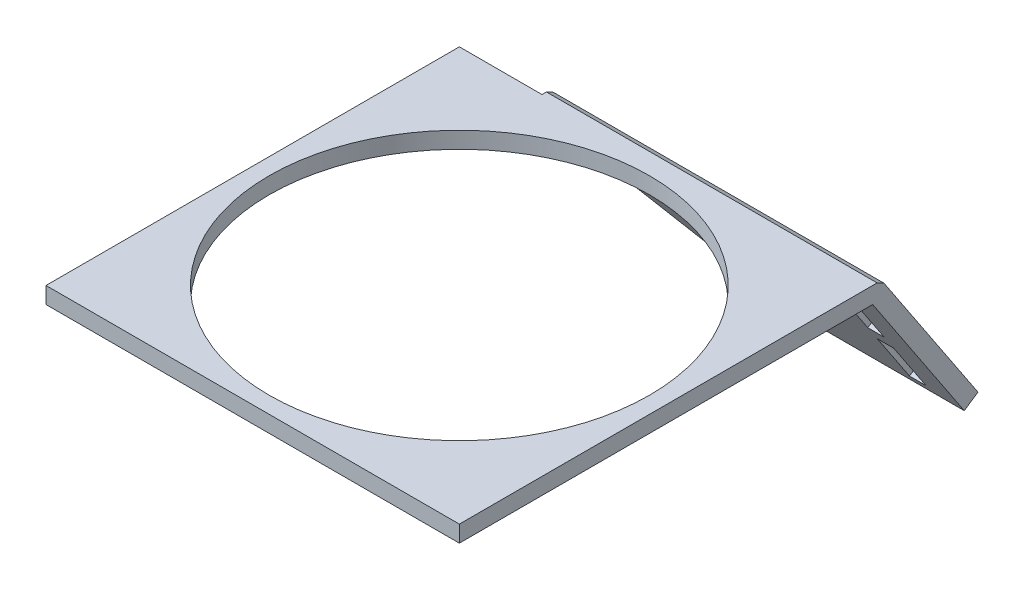
from build123d import *

# Parameters (mm, degrees)
SKETCH1_W           = 40
SKETCH1_H           = 40
SKETCH1_R           = 19
BOSS_EXTRUDE1_DEPTH = 1
BOSS_EXTRUDE3_DEPTH = 40
CUT_EXTRUDE1_DEPTH  = 40
SKETCH4_W           = 2
SKETCH4_H           = 17.959199538
CUT_EXTRUDE2_DEPTH  = 40
SKETCH5_W           = 4.291289536
SKETCH5_H           = 2.060082618
BOSS_EXTRUDE4_DEPTH = 1
SKETCH6_W           = 40
SKETCH6_H           = 40.535957941
SKETCH6_R           = 19
BOSS_EXTRUDE5_DEPTH = 1
SKETCH7_W           = 2
SKETCH7_H           = 8.850816201
SKETCH7_H_2         = 7.048300719
BOSS_EXTRUDE6_DEPTH = 1
BOSS_EXTRUDE7_DEPTH = 40
SKETCH9_W           = 50
SKETCH9_H           = 50
BOSS_EXTRUDE8_DEPTH = 2
SKETCH10_R          = 23
CUT_EXTRUDE3_DEPTH  = 2


with BuildPart() as part:
    # Sketch1 → Boss-Extrude1 (new body)
    with BuildSketch(Plane(origin=(0, 0, 0), x_dir=(1, 0, 0), z_dir=(0, 1, 0))):
        with Locations((-20, -4.822405003)):
            Rectangle(SKETCH1_W, SKETCH1_H)
        with Locations((-20, -4.822405003)):
            Circle(SKETCH1_R, mode=Mode.SUBTRACT)
    extrude(amount=BOSS_EXTRUDE1_DEPTH)

    # Sketch2 → Boss-Extrude3 (add)
    with BuildSketch(Plane(origin=(0, 0, 0), x_dir=(0, 0, -1), z_dir=(1, 0, 0))):
        Polygon((15.177594997, 0), (26.251567878, -16.654342515), (27.084285004, -16.100643871), (15.713552938, 1), (15.177594997, 1), align=None)
    extrude(amount=-BOSS_EXTRUDE3_DEPTH)

    # Sketch3 → Cut-Extrude1 (cut)
    with BuildSketch(Plane(origin=(0, 6.997999648, -10.524414707), x_dir=(1, 0, 0), z_dir=(0, -0.553698644, 0.832717126))):
        Polygon((-20, -28.40381377), (-40, -8.40381377), (-40, -28.40381377), align=None)
    extrude(amount=-CUT_EXTRUDE1_DEPTH, mode=Mode.SUBTRACT)

    # Sketch4 → Cut-Extrude2 (cut)
    with BuildSketch(Plane(origin=(0, 6.997999648, -10.524414707), x_dir=(1, 0, 0), z_dir=(0, -0.553698644, 0.832717126))):
        with Locations((-5, -18.291545123)):
            Rectangle(SKETCH4_W, SKETCH4_H)
    extrude(amount=-CUT_EXTRUDE2_DEPTH, mode=Mode.SUBTRACT)

    # Sketch5 → Boss-Extrude4 (add)
    with BuildSketch(Plane(origin=(0, 6.997999648, -10.524414707), x_dir=(1, 0, 0), z_dir=(0, -0.553698644, 0.832717126))):
        with Locations((-5.191272024, -19.192802864)):
            Rectangle(SKETCH5_W, SKETCH5_H)
    extrude(amount=-BOSS_EXTRUDE4_DEPTH)

    # Sketch6 → Boss-Extrude5 (add)
    with BuildSketch(Plane(origin=(0, 1, 0), x_dir=(1, 0, 0), z_dir=(0, 1, 0))):
        with Locations((-20, -4.554426032)):
            Rectangle(SKETCH6_W, SKETCH6_H)
        with Locations((-20, -4.822405003)):
            Circle(SKETCH6_R, mode=Mode.SUBTRACT)
    extrude(amount=BOSS_EXTRUDE5_DEPTH)

    # Sketch7 → Boss-Extrude6 (add)
    with BuildSketch(Plane(origin=(0, 7.551698292, -11.357131833), x_dir=(-1, 0, 0), z_dir=(0, 0.553698644, -0.832717126))):
        Polygon((40, -7.867855829), (40, -8.40381377), (20, -28.40381377), (0, -28.40381377), (0, -7.867855829), align=None)
        with Locations((5, -13.737353454)):
            Rectangle(SKETCH7_W, SKETCH7_H, mode=Mode.SUBTRACT)
        with Locations((5, -23.746994533)):
            Rectangle(SKETCH7_W, SKETCH7_H_2, mode=Mode.SUBTRACT)
    extrude(amount=BOSS_EXTRUDE6_DEPTH)

    # Sketch8 → Boss-Extrude7 (add)
    with BuildSketch(Plane(origin=(0, 0, 0), x_dir=(0, 0, -1), z_dir=(1, 0, 0))):
        Polygon((15.713552938, 2), (16.546270063, 1.553698644), (15.713552938, 1), align=None)
    extrude(amount=-BOSS_EXTRUDE7_DEPTH)

    # Sketch9 → Boss-Extrude8 (add)
    with BuildSketch(Plane(origin=(0, 0, 0), x_dir=(-1, 0, 0), z_dir=(0, -1, 0))):
        with Locations((25, -9.822405003)):
            Rectangle(SKETCH9_W, SKETCH9_H)
    extrude(amount=-BOSS_EXTRUDE8_DEPTH)

    # Sketch10 → Cut-Extrude3 (cut)
    with BuildSketch(Plane(origin=(0, 0, 0), x_dir=(-1, 0, 0), z_dir=(0, -1, 0))):
        with Locations((25, -9.822405003)):
            Circle(SKETCH10_R)
    extrude(amount=-CUT_EXTRUDE3_DEPTH, mode=Mode.SUBTRACT)


solid = part.part
